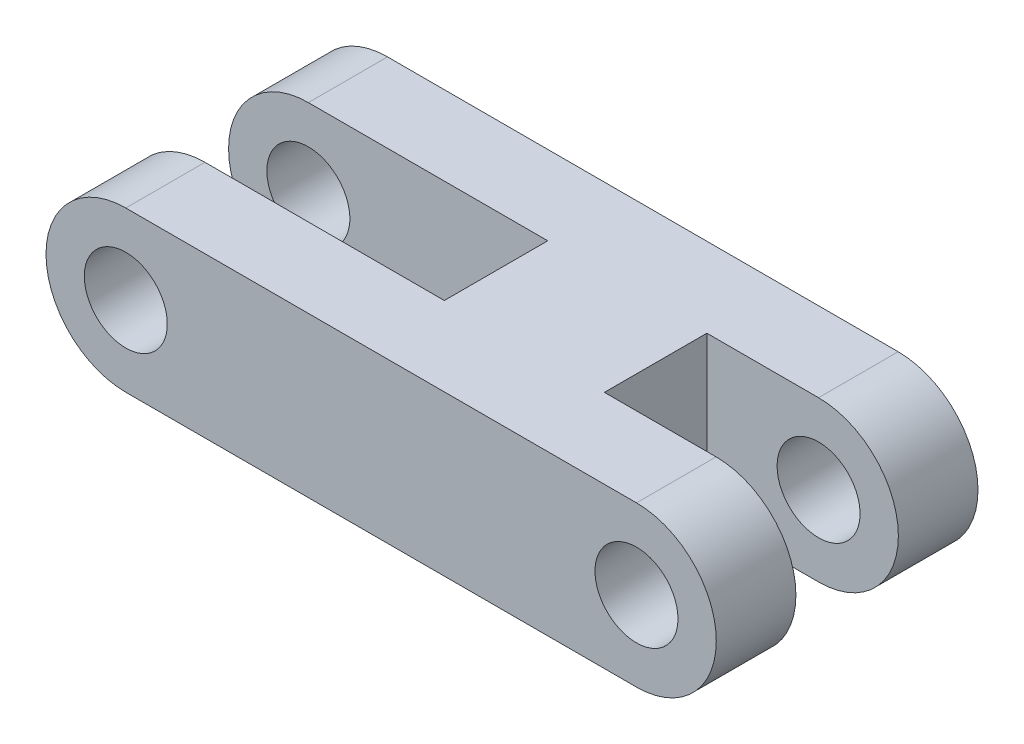
from build123d import *

# Parameters (mm, degrees)
SKETCH1_R           = 1.651
BOSS_EXTRUDE1_DEPTH = 10.414
SKETCH2_W           = 12.7
SKETCH2_H           = 4.1148
SKETCH2_H_2         = 4.0767
CUT_EXTRUDE1_DEPTH  = 7.35


with BuildPart() as part:
    # Sketch1 → Boss-Extrude1 (new body)
    with BuildSketch(Plane.XY):
        with BuildLine():
            Line((-71.178896696, 3.175), (-50.858896696, 3.175))
            ThreePointArc((-50.858896696, 3.175), (-47.683896696, 0), (-50.858896696, -3.175))
            Line((-50.858896696, -3.175), (-71.178896696, -3.175))
            ThreePointArc((-71.178896696, -3.175), (-74.353896696, 0), (-71.178896696, 3.175))
        make_face()
        with Locations((-50.858896696, 0)):
            Circle(SKETCH1_R, mode=Mode.SUBTRACT)
        with Locations((-71.178896696, 0)):
            Circle(SKETCH1_R, mode=Mode.SUBTRACT)
    extrude(amount=BOSS_EXTRUDE1_DEPTH)

    # Sketch2 → Cut-Extrude1 (cut, through all)
    with BuildSketch(Plane(origin=(0, 3.175, 0), x_dir=(1, 0, 0), z_dir=(0, 1, 0))):
        with Locations((-68.003896696, -5.207)):
            Rectangle(SKETCH2_W, SKETCH2_H)
        with Locations((-48.953896696, -5.207)):
            Rectangle(SKETCH2_W, SKETCH2_H_2)
    extrude(amount=-CUT_EXTRUDE1_DEPTH, mode=Mode.SUBTRACT)


solid = part.part
